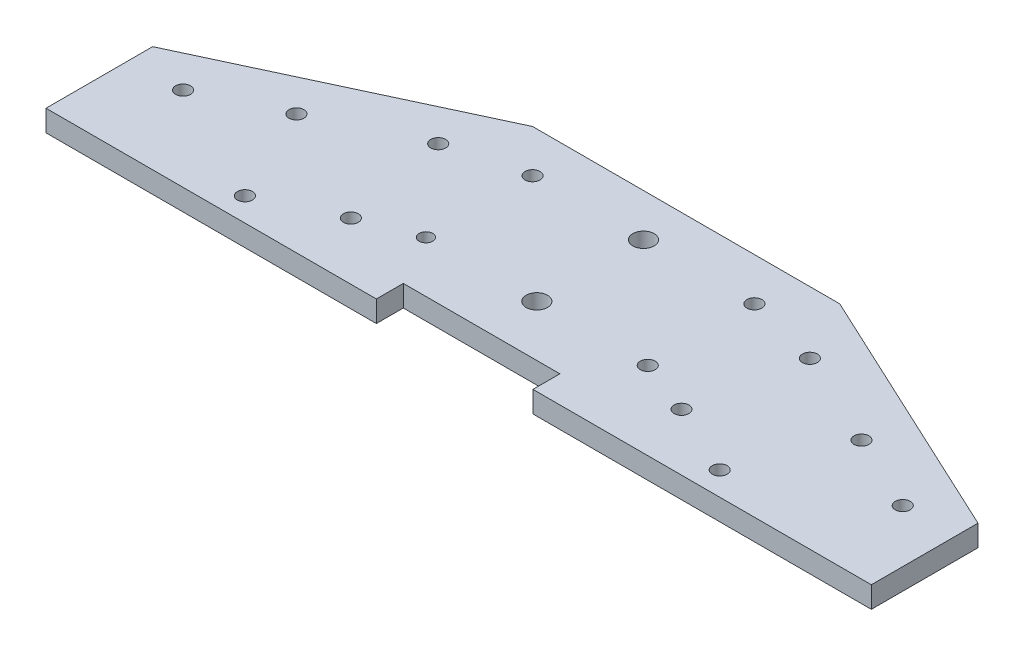
from build123d import *

# Parameters (mm, degrees)
SALIENTE_EXTRUIR1_DEPTH = 5
CORTAR_EXTRUIR1_REACH   = 7
CROQUIS2_R              = 1.75
CROQUIS2_R_2            = 2.5
CROQUIS2_R_3            = 1.599246839
CROQUIS3_W              = 36.7
CROQUIS3_H              = 6.315423537
CORTAR_EXTRUIR2_DEPTH   = 10


with BuildPart() as part:
    # Croquis1 → Saliente-Extruir1 (new body)
    with BuildSketch(Plane(origin=(0, 0, 0), x_dir=(1, 0, 0), z_dir=(0, 1, 0))):
        Polygon((36, 0), (-36, 0), (-96.722621731, -28.315423537), (-96.722621731, -53.315423537), (96.722621731, -53.315423537), (96.722621731, -28.315423537), align=None)
    extrude(amount=SALIENTE_EXTRUIR1_DEPTH)

    # Croquis2 → Cortar-Extruir1 (cut, up to next)
    with BuildSketch(Plane(origin=(0, 5, 0), x_dir=(1, 0, 0), z_dir=(0, 1, 0)), mode=Mode.PRIVATE) as cortar_extruir1_sk1:
        with Locations((-84.339669031, -33.574937051)):
            Circle(CROQUIS2_R)
    cortar_extruir1_tool1 = extrude(cortar_extruir1_sk1.sketch, amount=-CORTAR_EXTRUIR1_REACH, mode=Mode.PRIVATE) & part.part
    add(cortar_extruir1_tool1.solids().sort_by_distance((-84.339669, 5, 33.574937))[0], mode=Mode.SUBTRACT)
    # Croquis2 → Cortar-Extruir1 (cut, up to next)
    with BuildSketch(Plane(origin=(0, 5, 0), x_dir=(1, 0, 0), z_dir=(0, 1, 0)), mode=Mode.PRIVATE) as cortar_extruir1_sk2:
        with Locations((-66.21351329, -25.122571817)):
            Circle(CROQUIS2_R)
    cortar_extruir1_tool2 = extrude(cortar_extruir1_sk2.sketch, amount=-CORTAR_EXTRUIR1_REACH, mode=Mode.PRIVATE) & part.part
    add(cortar_extruir1_tool2.solids().sort_by_distance((-66.213513, 5, 25.122572))[0], mode=Mode.SUBTRACT)
    # Croquis2 → Cortar-Extruir1 (cut, up to next)
    with BuildSketch(Plane(origin=(0, 5, 0), x_dir=(1, 0, 0), z_dir=(0, 1, 0)), mode=Mode.PRIVATE) as cortar_extruir1_sk3:
        with Locations((-55.648056746, -47.780266492)):
            Circle(CROQUIS2_R)
    cortar_extruir1_tool3 = extrude(cortar_extruir1_sk3.sketch, amount=-CORTAR_EXTRUIR1_REACH, mode=Mode.PRIVATE) & part.part
    add(cortar_extruir1_tool3.solids().sort_by_distance((-55.648057, 5, 47.780266))[0], mode=Mode.SUBTRACT)
    # Croquis2 → Cortar-Extruir1 (cut, up to next)
    with BuildSketch(Plane(origin=(0, 5, 0), x_dir=(1, 0, 0), z_dir=(0, 1, 0)), mode=Mode.PRIVATE) as cortar_extruir1_sk4:
        with Locations((-38.701346441, -39.877885696)):
            Circle(CROQUIS2_R)
    cortar_extruir1_tool4 = extrude(cortar_extruir1_sk4.sketch, amount=-CORTAR_EXTRUIR1_REACH, mode=Mode.PRIVATE) & part.part
    add(cortar_extruir1_tool4.solids().sort_by_distance((-38.701346, 5, 39.877886))[0], mode=Mode.SUBTRACT)
    # Croquis2 → Cortar-Extruir1 (cut, up to next)
    with BuildSketch(Plane(origin=(0, 5, 0), x_dir=(1, 0, 0), z_dir=(0, 1, 0)), mode=Mode.PRIVATE) as cortar_extruir1_sk5:
        with Locations((-43.555818614, -14.557115273)):
            Circle(CROQUIS2_R)
    cortar_extruir1_tool5 = extrude(cortar_extruir1_sk5.sketch, amount=-CORTAR_EXTRUIR1_REACH, mode=Mode.PRIVATE) & part.part
    add(cortar_extruir1_tool5.solids().sort_by_distance((-43.555819, 5, 14.557115))[0], mode=Mode.SUBTRACT)
    # Croquis2 → Cortar-Extruir1 (cut, up to next)
    with BuildSketch(Plane(origin=(0, 5, 0), x_dir=(1, 0, 0), z_dir=(0, 1, 0)), mode=Mode.PRIVATE) as cortar_extruir1_sk6:
        with Locations((38.868873457, -39.956004827)):
            Circle(CROQUIS2_R)
    cortar_extruir1_tool6 = extrude(cortar_extruir1_sk6.sketch, amount=-CORTAR_EXTRUIR1_REACH, mode=Mode.PRIVATE) & part.part
    add(cortar_extruir1_tool6.solids().sort_by_distance((38.868873, 5, 39.956005))[0], mode=Mode.SUBTRACT)
    # Croquis2 → Cortar-Extruir1 (cut, up to next)
    with BuildSketch(Plane(origin=(0, 5, 0), x_dir=(1, 0, 0), z_dir=(0, 1, 0)), mode=Mode.PRIVATE) as cortar_extruir1_sk7:
        with Locations((55.648056746, -47.780266492)):
            Circle(CROQUIS2_R)
    cortar_extruir1_tool7 = extrude(cortar_extruir1_sk7.sketch, amount=-CORTAR_EXTRUIR1_REACH, mode=Mode.PRIVATE) & part.part
    add(cortar_extruir1_tool7.solids().sort_by_distance((55.648057, 5, 47.780266))[0], mode=Mode.SUBTRACT)
    # Croquis2 → Cortar-Extruir1 (cut, up to next)
    with BuildSketch(Plane(origin=(0, 5, 0), x_dir=(1, 0, 0), z_dir=(0, 1, 0)), mode=Mode.PRIVATE) as cortar_extruir1_sk8:
        with Locations((84.339669031, -33.574937051)):
            Circle(CROQUIS2_R)
    cortar_extruir1_tool8 = extrude(cortar_extruir1_sk8.sketch, amount=-CORTAR_EXTRUIR1_REACH, mode=Mode.PRIVATE) & part.part
    add(cortar_extruir1_tool8.solids().sort_by_distance((84.339669, 5, 33.574937))[0], mode=Mode.SUBTRACT)
    # Croquis2 → Cortar-Extruir1 (cut, up to next)
    with BuildSketch(Plane(origin=(0, 5, 0), x_dir=(1, 0, 0), z_dir=(0, 1, 0)), mode=Mode.PRIVATE) as cortar_extruir1_sk9:
        with Locations((66.21351329, -25.122571817)):
            Circle(CROQUIS2_R)
    cortar_extruir1_tool9 = extrude(cortar_extruir1_sk9.sketch, amount=-CORTAR_EXTRUIR1_REACH, mode=Mode.PRIVATE) & part.part
    add(cortar_extruir1_tool9.solids().sort_by_distance((66.213513, 5, 25.122572))[0], mode=Mode.SUBTRACT)
    # Croquis2 → Cortar-Extruir1 (cut, up to next)
    with BuildSketch(Plane(origin=(0, 5, 0), x_dir=(1, 0, 0), z_dir=(0, 1, 0)), mode=Mode.PRIVATE) as cortar_extruir1_sk10:
        with Locations((43.555818614, -14.557115273)):
            Circle(CROQUIS2_R)
    cortar_extruir1_tool10 = extrude(cortar_extruir1_sk10.sketch, amount=-CORTAR_EXTRUIR1_REACH, mode=Mode.PRIVATE) & part.part
    add(cortar_extruir1_tool10.solids().sort_by_distance((43.555819, 5, 14.557115))[0], mode=Mode.SUBTRACT)
    # Croquis2 → Cortar-Extruir1 (cut, up to next)
    with BuildSketch(Plane(origin=(0, 5, 0), x_dir=(1, 0, 0), z_dir=(0, 1, 0)), mode=Mode.PRIVATE) as cortar_extruir1_sk11:
        with Locations((0, -10)):
            Circle(CROQUIS2_R_2)
    cortar_extruir1_tool11 = extrude(cortar_extruir1_sk11.sketch, amount=-CORTAR_EXTRUIR1_REACH, mode=Mode.PRIVATE) & part.part
    add(cortar_extruir1_tool11.solids().sort_by_distance((0, 5, 10))[0], mode=Mode.SUBTRACT)
    # Croquis2 → Cortar-Extruir1 (cut, up to next)
    with BuildSketch(Plane(origin=(0, 5, 0), x_dir=(1, 0, 0), z_dir=(0, 1, 0)), mode=Mode.PRIVATE) as cortar_extruir1_sk12:
        with Locations((0, -35)):
            Circle(CROQUIS2_R_2)
    cortar_extruir1_tool12 = extrude(cortar_extruir1_sk12.sketch, amount=-CORTAR_EXTRUIR1_REACH, mode=Mode.PRIVATE) & part.part
    add(cortar_extruir1_tool12.solids().sort_by_distance((0, 5, 35))[0], mode=Mode.SUBTRACT)
    # Croquis2 → Cortar-Extruir1 (cut, up to next)
    with BuildSketch(Plane(origin=(0, 5, 0), x_dir=(1, 0, 0), z_dir=(0, 1, 0)), mode=Mode.PRIVATE) as cortar_extruir1_sk13:
        with Locations((26, -10)):
            Circle(CROQUIS2_R)
    cortar_extruir1_tool13 = extrude(cortar_extruir1_sk13.sketch, amount=-CORTAR_EXTRUIR1_REACH, mode=Mode.PRIVATE) & part.part
    add(cortar_extruir1_tool13.solids().sort_by_distance((26, 5, 10))[0], mode=Mode.SUBTRACT)
    # Croquis2 → Cortar-Extruir1 (cut, up to next)
    with BuildSketch(Plane(origin=(0, 5, 0), x_dir=(1, 0, 0), z_dir=(0, 1, 0)), mode=Mode.PRIVATE) as cortar_extruir1_sk14:
        with Locations((26, -35)):
            Circle(CROQUIS2_R)
    cortar_extruir1_tool14 = extrude(cortar_extruir1_sk14.sketch, amount=-CORTAR_EXTRUIR1_REACH, mode=Mode.PRIVATE) & part.part
    add(cortar_extruir1_tool14.solids().sort_by_distance((26, 5, 35))[0], mode=Mode.SUBTRACT)
    # Croquis2 → Cortar-Extruir1 (cut, up to next)
    with BuildSketch(Plane(origin=(0, 5, 0), x_dir=(1, 0, 0), z_dir=(0, 1, 0)), mode=Mode.PRIVATE) as cortar_extruir1_sk15:
        with Locations((-26, -10)):
            Circle(CROQUIS2_R)
    cortar_extruir1_tool15 = extrude(cortar_extruir1_sk15.sketch, amount=-CORTAR_EXTRUIR1_REACH, mode=Mode.PRIVATE) & part.part
    add(cortar_extruir1_tool15.solids().sort_by_distance((-26, 5, 10))[0], mode=Mode.SUBTRACT)
    # Croquis2 → Cortar-Extruir1 (cut, up to next)
    with BuildSketch(Plane(origin=(0, 5, 0), x_dir=(1, 0, 0), z_dir=(0, 1, 0)), mode=Mode.PRIVATE) as cortar_extruir1_sk16:
        with Locations((-26, -35)):
            Circle(CROQUIS2_R_3)
    cortar_extruir1_tool16 = extrude(cortar_extruir1_sk16.sketch, amount=-CORTAR_EXTRUIR1_REACH, mode=Mode.PRIVATE) & part.part
    add(cortar_extruir1_tool16.solids().sort_by_distance((-26, 5, 35))[0], mode=Mode.SUBTRACT)

    # Croquis3 → Cortar-Extruir2 (cut)
    with BuildSketch(Plane(origin=(0, 5, 0), x_dir=(1, 0, 0), z_dir=(0, 1, 0))):
        with Locations((-0.941024734, -50.157711769)):
            Rectangle(CROQUIS3_W, CROQUIS3_H)
    extrude(amount=-CORTAR_EXTRUIR2_DEPTH, mode=Mode.SUBTRACT)


solid = part.part
